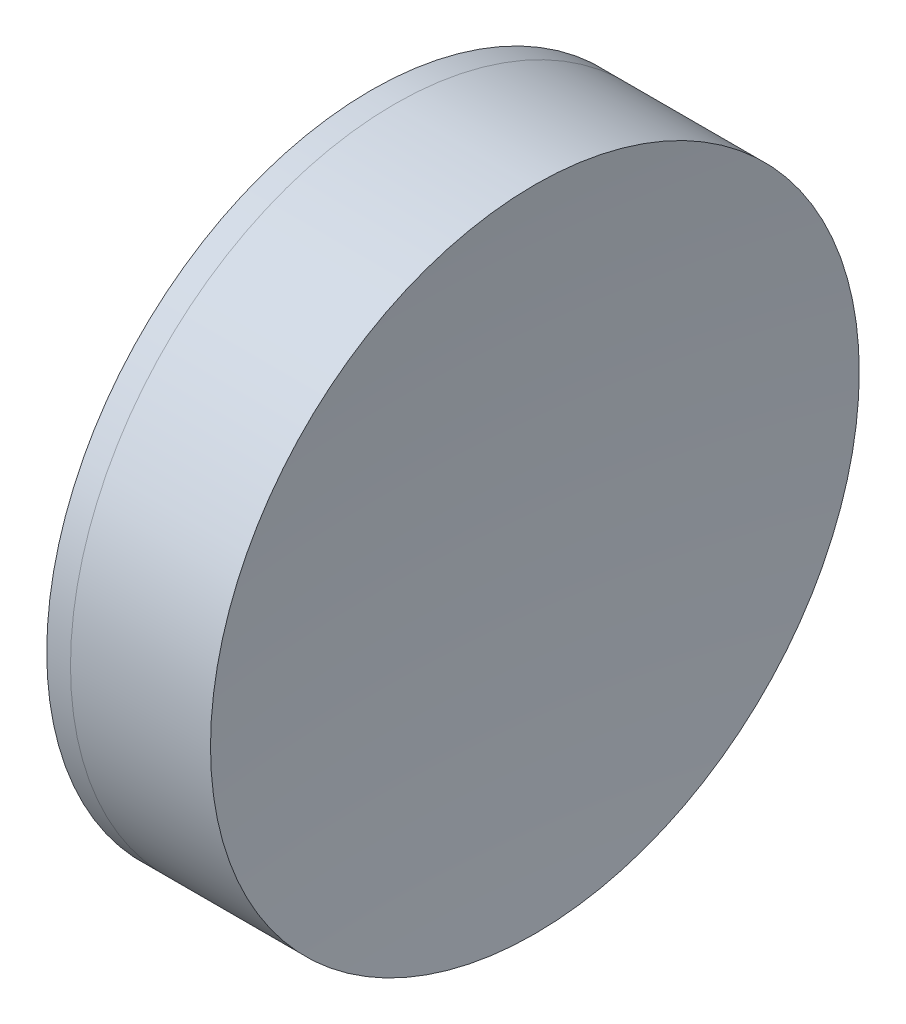
from build123d import *


with BuildPart() as part:
    # 草图1 one side → 旋转1 (revolve)
    with BuildSketch(Plane(origin=(0, 0, 0), x_dir=(1, 0, 0), z_dir=(0, 1, 0)), mode=Mode.PRIVATE) as revolve_1_sk:
        with BuildLine():
            ThreePointArc((101.824611547, 25.4), (95.927403852, 13.30370255), (93.900344633, 0))
            Line((93.900344633, 0), (110.900344633, 0))
            ThreePointArc((110.900344633, 0), (109.061276684, 13.202597256), (103.684092333, 25.4))
            Line((103.684092333, 25.4), (101.824611547, 25.4))
        make_face()
    revolve(revolve_1_sk.sketch.rotate(Axis((-0.816062176, 0, 0), (1, 0, 0)), 180), axis=Axis((-0.816062176, 0, 0), (1, 0, 0)))  # turned: the seam where the file's is


with BuildPart() as body_2:
    # 草图2 one side → 旋转2 (revolve)
    with BuildSketch(Plane(origin=(0, 0, 0), x_dir=(1, 0, 0), z_dir=(0, 1, 0)), mode=Mode.PRIVATE) as revolve_2_sk:
        with BuildLine():
            Line((114.64690189, 25.4), (103.684092333, 25.4))
            ThreePointArc((103.684092333, 25.4), (109.061276684, 13.202597256), (110.900344633, 0))
            Line((110.900344633, 0), (113.400344633, 0))
            ThreePointArc((113.400344633, 0), (113.712171372, 12.715285142), (114.64690189, 25.4))
        make_face()
    revolve(revolve_2_sk.sketch.rotate(Axis((-0.551919993, 0, 0), (1, 0, 0)), 180), axis=Axis((-0.551919993, 0, 0), (1, 0, 0)))  # turned: the seam where the file's is


solid = Compound([part.part, body_2.part])
